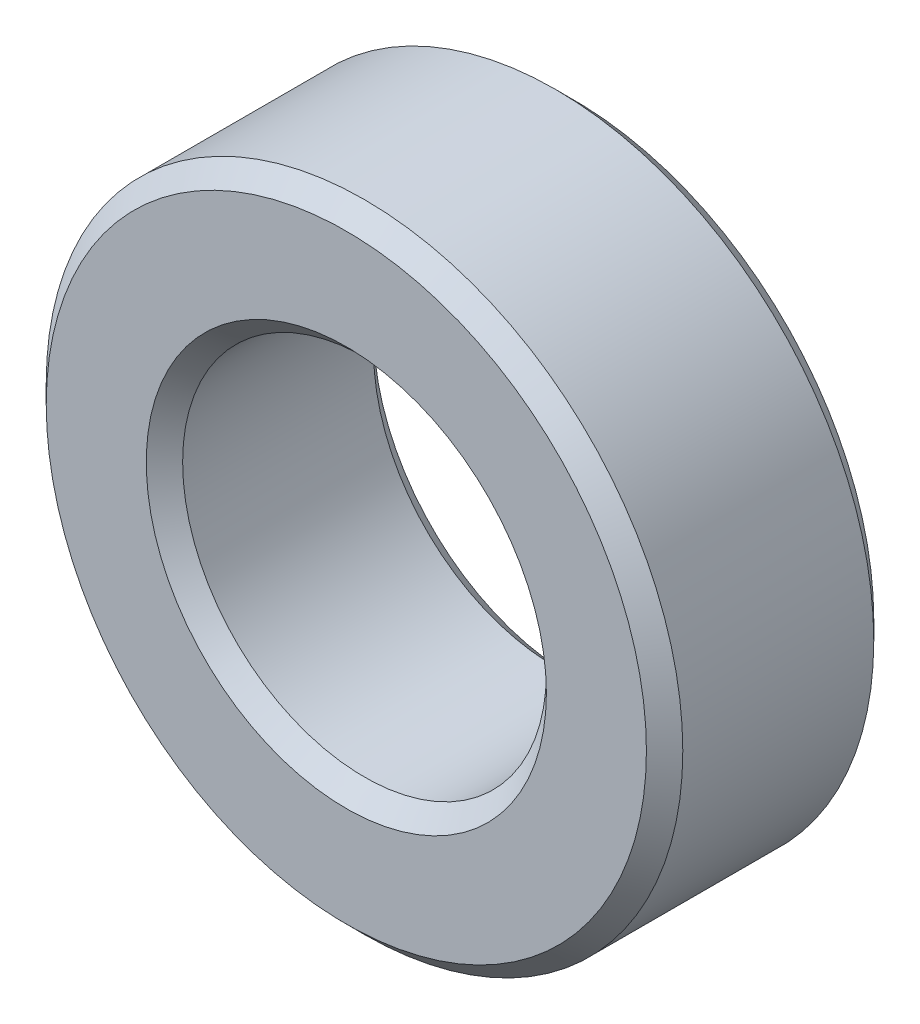
from build123d import *

# Parameters (mm, degrees)
SKETCH1_R           = 3.5
SKETCH1_R_2         = 2
BOSS_EXTRUDE1_DEPTH = 2.5
CHAMFER1_SIZE       = 0.2


with BuildPart() as part:
    # Sketch1 → Boss-Extrude1 (new body)
    with BuildSketch(Plane.XY):
        Circle(SKETCH1_R)
        Circle(SKETCH1_R_2, mode=Mode.SUBTRACT)
    extrude(amount=BOSS_EXTRUDE1_DEPTH)

    # Chamfer1
    chamfer1_edges = [part.edges().sort_by_distance(p)[0] for p in [
        (-3.5, 0, 0),
        (-3.5, 0, 2.5),
        (-2, 0, 0),
        (-2, 0, 2.5),
    ]]
    chamfer(chamfer1_edges, length=CHAMFER1_SIZE)


solid = part.part
